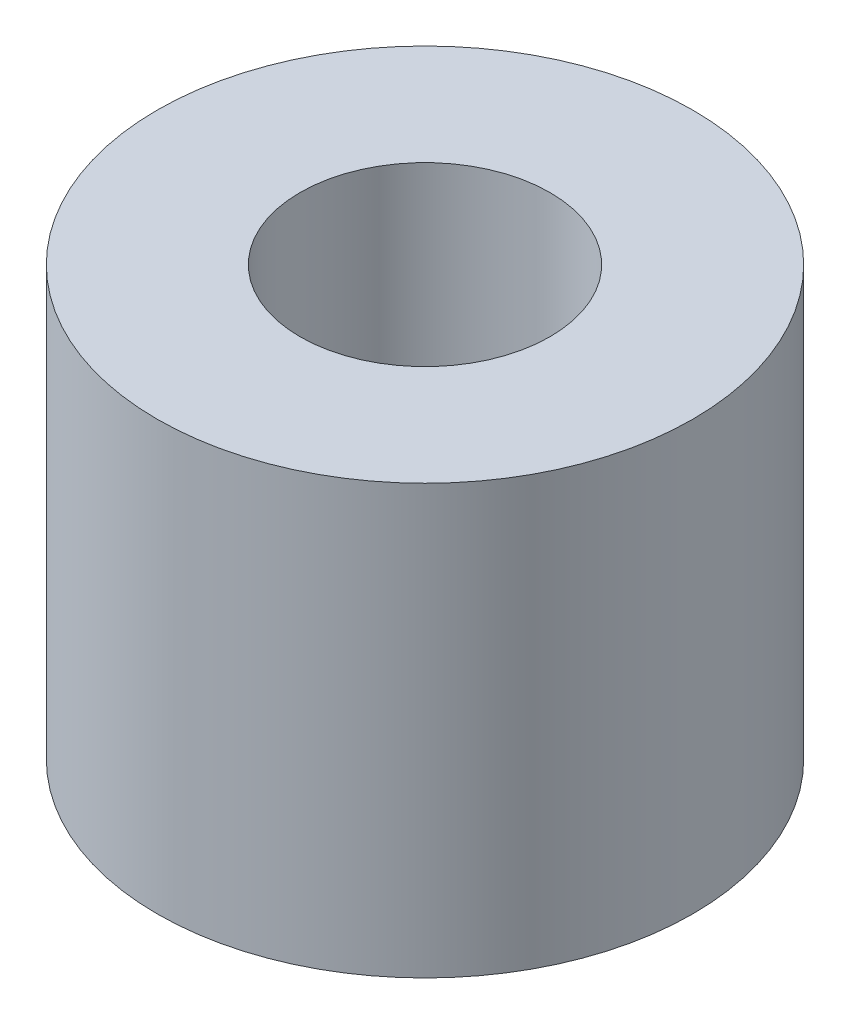
from build123d import *

# Parameters (mm, degrees)
SKETCH1_R           = 3.75
SKETCH1_R_2         = 1.75
BOSS_EXTRUDE1_DEPTH = 6


with BuildPart() as part:
    # Sketch1 → Boss-Extrude1 (new body)
    with BuildSketch(Plane(origin=(0, 0, 0), x_dir=(1, 0, 0), z_dir=(0, 1, 0))):
        Circle(SKETCH1_R)
        Circle(SKETCH1_R_2, mode=Mode.SUBTRACT)
    extrude(amount=BOSS_EXTRUDE1_DEPTH)


solid = part.part
